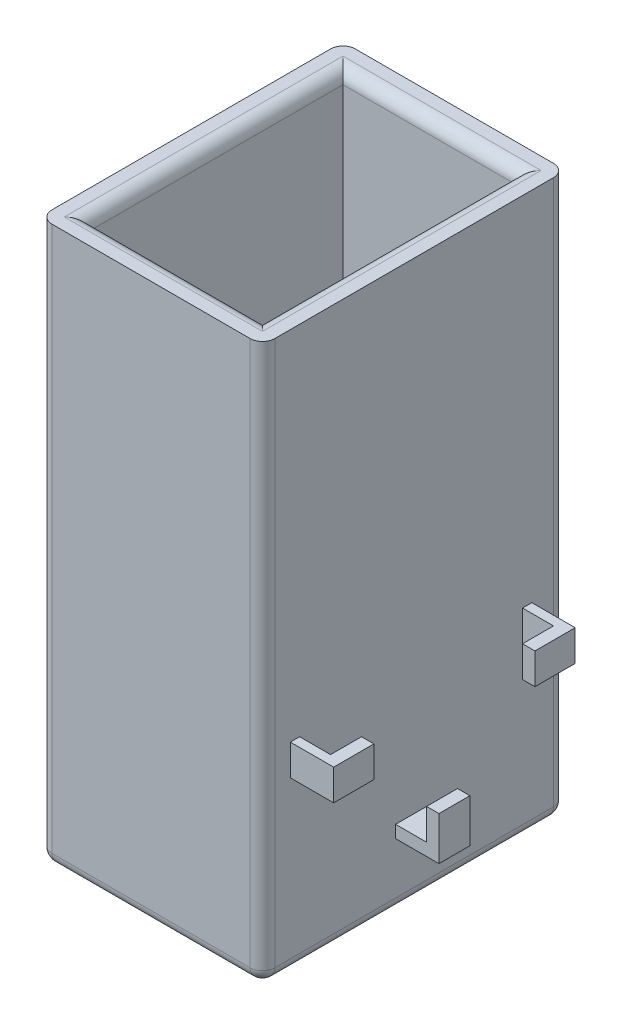
from build123d import *

# Parameters (mm, degrees)
SKETCH1_W           = 36
SKETCH1_H           = 49
BOSS_EXTRUDE2_DEPTH = 90
SHELL3_T            = -4
FILLET1_R           = 2
FILLET2_R           = 2
FILLET3_R           = 2
FILLET4_R           = 2
FILLET5_R           = 2
SKETCH7_W           = 1.5
SKETCH7_H           = 5
SKETCH7_W_2         = 1.499999997
SKETCH7_W_3         = 5
SKETCH7_H_2         = 2
BOSS_EXTRUDE3_DEPTH = 7
SKETCH8_W           = 2
SKETCH8_H           = 5
BOSS_EXTRUDE4_DEPTH = 5
SKETCH9_W           = 2
SKETCH9_H           = 5
BOSS_EXTRUDE5_DEPTH = 5
SKETCH10_W          = 2
SKETCH10_H          = 5
BOSS_EXTRUDE6_DEPTH = 5
FILLET7_R           = 2
FILLET8_R           = 2
FILLET9_R           = 2
FILLET10_R          = 2


with BuildPart() as part:
    # Sketch1 → Boss-Extrude2 (new body)
    with BuildSketch(Plane(origin=(0, 0, 0), x_dir=(1, 0, 0), z_dir=(0, 1, 0))):
        with Locations((3.176470588, -4.072192513)):
            Rectangle(SKETCH1_W, SKETCH1_H)
    extrude(amount=BOSS_EXTRUDE2_DEPTH)

    # Shell3
    shell3_openings = [part.faces().sort_by_distance(p)[0] for p in [
        (3.176470588, 90, 4.072192513),
    ]]
    offset(amount=SHELL3_T, openings=shell3_openings, kind=Kind.INTERSECTION)

    # Fillet1
    fillet1_edges = [part.edges().sort_by_distance(p)[0] for p in [
        (-14.823529412, 45, -20.427807487),
    ]]
    fillet(fillet1_edges, radius=FILLET1_R)

    # Fillet2
    fillet2_edges = [part.edges().sort_by_distance(p)[0] for p in [
        (21.176470588, 45, -20.427807487),
    ]]
    fillet(fillet2_edges, radius=FILLET2_R)

    # Fillet3
    fillet3_edges = [part.edges().sort_by_distance(p)[0] for p in [
        (21.176470588, 45, 28.572192513),
    ]]
    fillet(fillet3_edges, radius=FILLET3_R)

    # Fillet4
    fillet4_edges = [part.edges().sort_by_distance(p)[0] for p in [
        (-14.823529412, 45, 28.572192513),
    ]]
    fillet(fillet4_edges, radius=FILLET4_R)

    # Fillet5
    fillet5_edges = [part.edges().sort_by_distance(p)[0] for p in [
        (-14.823529412, 0, 4.072192513),
        (3.176470588, 0, -20.427807487),
        (21.176470588, 0, 4.072192513),
        (3.176470588, 0, 28.572192513),
    ]]
    fillet(fillet5_edges, radius=FILLET5_R)

    # Sketch7 → Boss-Extrude3 (add)
    with BuildSketch(Plane(origin=(21.176470588, 0, 0), x_dir=(0, 0, -1), z_dir=(1, 0, 0))):
        with Locations((-23.322192513, 29.805726248)):
            Rectangle(SKETCH7_W, SKETCH7_H)
        with Locations((14.177807489, 29.805726248)):
            Rectangle(SKETCH7_W_2, SKETCH7_H)
        with Locations((-4.572192513, 11.305726248)):
            Rectangle(SKETCH7_W_3, SKETCH7_H_2)
    extrude(amount=BOSS_EXTRUDE3_DEPTH)

    # Sketch8 → Boss-Extrude4 (add)
    with BuildSketch(Plane(origin=(0, 0, 22.572192513), x_dir=(-1, 0, 0), z_dir=(0, 0, -1))):
        with Locations((-27.176470588, 29.805726248)):
            Rectangle(SKETCH8_W, SKETCH8_H)
    extrude(amount=BOSS_EXTRUDE4_DEPTH)

    # Sketch9 → Boss-Extrude5 (add)
    with BuildSketch(Plane.XY.offset(-13.42780749)):
        with Locations((27.176470588, 29.805726248)):
            Rectangle(SKETCH9_W, SKETCH9_H)
    extrude(amount=BOSS_EXTRUDE5_DEPTH)

    # Sketch10 → Boss-Extrude6 (add)
    with BuildSketch(Plane(origin=(0, 12.305726248, 0), x_dir=(1, 0, 0), z_dir=(0, 1, 0))):
        with Locations((27.176470588, -4.572192513)):
            Rectangle(SKETCH10_W, SKETCH10_H)
    extrude(amount=BOSS_EXTRUDE6_DEPTH)

    # Fillet7
    fillet7_edges = [part.edges().sort_by_distance(p)[0] for p in [
        (17.176470588, 90, 4.072192513),
    ]]
    fillet(fillet7_edges, radius=FILLET7_R)

    # Fillet8
    fillet8_edges = [part.edges().sort_by_distance(p)[0] for p in [
        (3.176470588, 90, -16.427807487),
    ]]
    fillet(fillet8_edges, radius=FILLET8_R)

    # Fillet9
    fillet9_edges = [part.edges().sort_by_distance(p)[0] for p in [
        (-10.823529412, 90, 4.072192513),
    ]]
    fillet(fillet9_edges, radius=FILLET9_R)

    # Fillet10
    fillet10_edges = [part.edges().sort_by_distance(p)[0] for p in [
        (3.176470588, 90, 24.572192513),
    ]]
    fillet(fillet10_edges, radius=FILLET10_R)


solid = part.part
